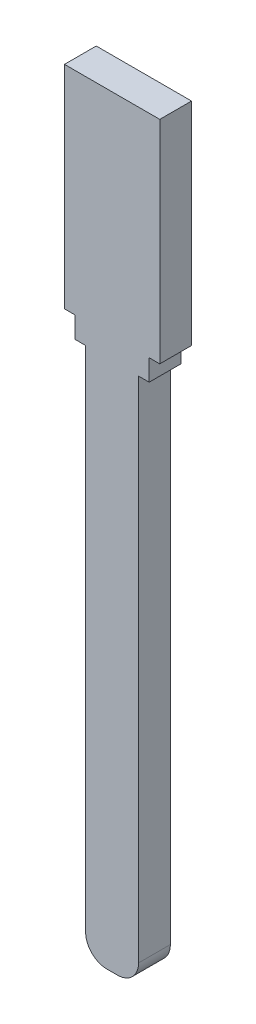
from build123d import *

# Parameters (mm, degrees)
SALIENTE_EXTRUIR1_DEPTH = 3


with BuildPart() as part:
    # Model → Saliente-Extruir1 (new body)
    with BuildSketch(Plane.XY):
        with BuildLine():
            Line((-36.413611368, 21.5), (-36.413611368, 15.5))
            Line((-36.413611368, 15.5), (-36.413611368, 1.5))
            Line((-36.413611368, 1.5), (-37.413611368, 1.5))
            Line((-37.413611368, 1.5), (-37.413611368, -0.5))
            Line((-37.413611368, -0.5), (-38.413611368, -0.5))
            Line((-38.413611368, -0.5), (-38.413611368, -48.5))
            ThreePointArc((-38.413611368, -48.5), (-38.999397805, -49.914213562), (-40.413611368, -50.5))
            Line((-40.413611368, -50.5), (-41.413611368, -50.5))
            ThreePointArc((-41.413611368, -50.5), (-42.82782493, -49.914213562), (-43.413611368, -48.5))
            Line((-43.413611368, -48.5), (-43.413611368, -0.5))
            Line((-43.413611368, -0.5), (-44.413611368, -0.5))
            Line((-44.413611368, -0.5), (-44.413611368, 1.5))
            Line((-44.413611368, 1.5), (-45.413611368, 1.5))
            Line((-45.413611368, 1.5), (-45.413611368, 21.5))
            Line((-45.413611368, 21.5), (-36.413611368, 21.5))
        make_face()
    extrude(amount=SALIENTE_EXTRUIR1_DEPTH)


solid = part.part
